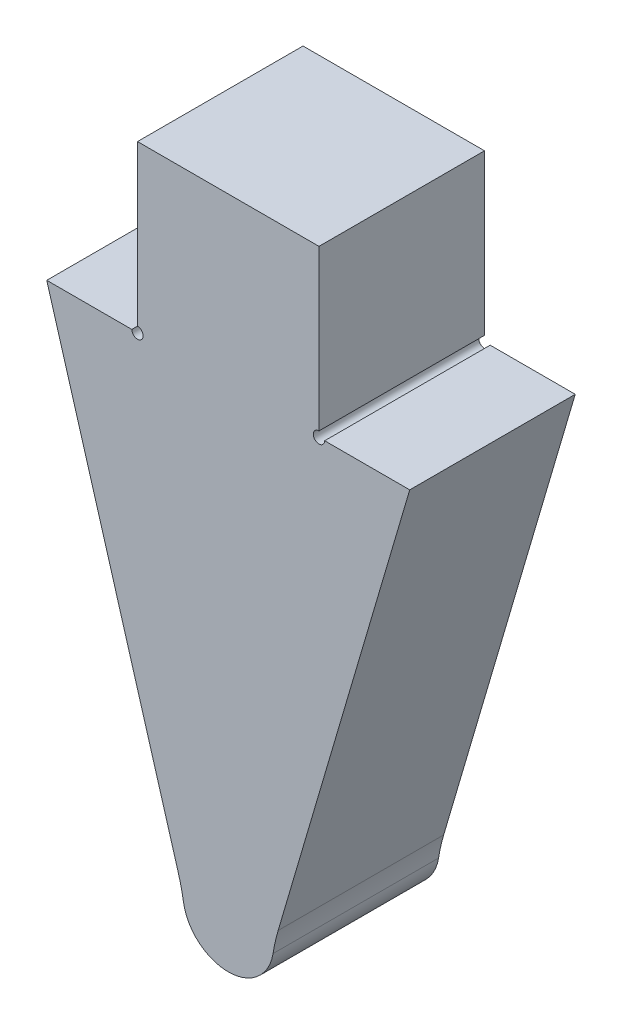
from build123d import *

# Parameters (mm, degrees)
BOSS_EXTRUDE1_DEPTH = 5.7912
FILLET1_R           = 6.35
SKETCH2_R           = 0.1984375
CUT_EXTRUDE1_DEPTH  = 6.7912


with BuildPart() as part:
    # Sketch1 → Boss-Extrude1 (new body)
    with BuildSketch(Plane.XY):
        with BuildLine():
            Line((-6.35, 0), (-9.525, 0))
            Line((-9.525, 0), (-4.7625, -16.1925))
            ThreePointArc((-4.7625, -16.1925), (-3.175, -17.78), (-1.5875, -16.1925))
            Line((-1.5875, -16.1925), (3.175, 0))
            Line((3.175, 0), (0, 0))
            Line((0, 0), (0, 5.7912))
            Line((0, 5.7912), (-6.35, 5.7912))
            Line((-6.35, 5.7912), (-6.35, 0))
        make_face()
    extrude(amount=BOSS_EXTRUDE1_DEPTH)

    # Fillet1
    fillet1_edges = [part.edges().sort_by_distance(p)[0] for p in [
        (-1.5875, -16.1925, 2.8956),
        (-4.7625, -16.1925, 2.8956),
    ]]
    fillet(fillet1_edges, radius=FILLET1_R)

    # Sketch2 → Cut-Extrude1 (cut, through all)
    with BuildSketch(Plane.XY.offset(5.7912)):
        with Locations((-6.35, 0)):
            Circle(SKETCH2_R)
        Circle(SKETCH2_R)
    extrude(amount=-CUT_EXTRUDE1_DEPTH, mode=Mode.SUBTRACT)


solid = part.part
